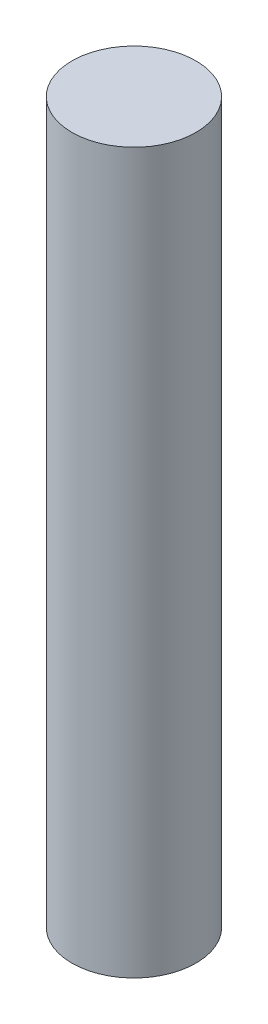
from build123d import *

# Parameters (mm, degrees)
SKETCH1_R           = 5
BOSS_EXTRUDE1_DEPTH = 58


with BuildPart() as part:
    # Sketch1 → Boss-Extrude1 (new body)
    with BuildSketch(Plane(origin=(0, 0, 0), x_dir=(1, 0, 0), z_dir=(0, 1, 0))):
        Circle(SKETCH1_R)
    extrude(amount=BOSS_EXTRUDE1_DEPTH)


solid = part.part
